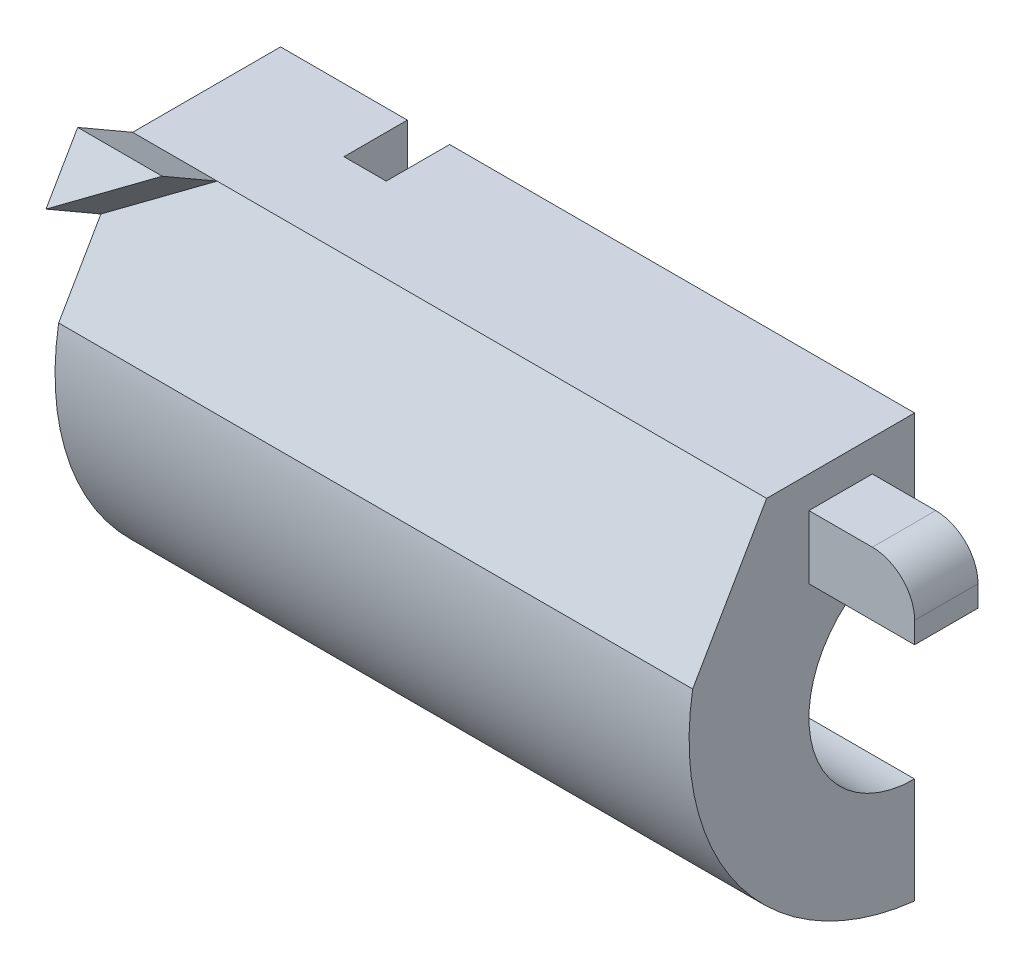
from build123d import *

# Parameters (mm, degrees)
BOSS_EXTRUDE1_DEPTH = 30
CUT_EXTRUDE1_DEPTH  = 10
CUT_EXTRUDE2_DEPTH  = 10
SKETCH5_W           = 3
SKETCH5_H           = 3
BOSS_EXTRUDE2_DEPTH = 5
FILLET2_R           = 2
SKETCH7_W           = 2
SKETCH7_H           = 3
CUT_EXTRUDE3_DEPTH  = 8.5
BOSS_EXTRUDE3_DEPTH = 3


with BuildPart() as part:
    # Sketch2 → Boss-Extrude1 (new body)
    with BuildSketch(Plane(origin=(0, 0, 0), x_dir=(0, 0, -1), z_dir=(1, 0, 0))):
        with BuildLine():
            Line((0, -10), (0, 10))
            Line((0, 10), (-7, 10))
            Line((-7, 10), (-10.5, 3.937822174))
            ThreePointArc((-10.5, 3.937822174), (-8.25442165, -5.294457389), (0, -10))
        make_face()
    extrude(amount=-BOSS_EXTRUDE1_DEPTH)

    # Sketch3 → Cut-Extrude1 (cut)
    with BuildSketch(Plane(origin=(0, 0, 0), x_dir=(0, 0, -1), z_dir=(1, 0, 0))):
        with BuildLine():
            Line((0, -5), (0, 5))
            ThreePointArc((0, 5), (-5, 0), (0, -5))
        make_face()
    extrude(amount=-CUT_EXTRUDE1_DEPTH, mode=Mode.SUBTRACT)

    # Sketch4 → Cut-Extrude2 (cut)
    with BuildSketch(Plane.ZY.offset(30)):
        with BuildLine():
            Line((0, -3), (0, 3))
            ThreePointArc((0, 3), (3, 0), (0, -3))
        make_face()
    extrude(amount=-CUT_EXTRUDE2_DEPTH, mode=Mode.SUBTRACT)

    # Sketch5 → Boss-Extrude2 (add)
    with BuildSketch(Plane(origin=(0, 0, 0), x_dir=(0, 0, -1), z_dir=(1, 0, 0))):
        with Locations((-3.5, 7)):
            Rectangle(SKETCH5_W, SKETCH5_H)
    extrude(amount=BOSS_EXTRUDE2_DEPTH)

    # Fillet2
    fillet2_edges = [part.edges().sort_by_distance(p)[0] for p in [
        (5, 8.5, 3.5),
    ]]
    fillet(fillet2_edges, radius=FILLET2_R)

    # Sketch7 → Cut-Extrude3 (cut)
    with BuildSketch(Plane(origin=(0, 10, 0), x_dir=(1, 0, 0), z_dir=(0, 1, 0))):
        with Locations((-23, -1.5)):
            Rectangle(SKETCH7_W, SKETCH7_H)
    extrude(amount=-CUT_EXTRUDE3_DEPTH, mode=Mode.SUBTRACT)

    # Sketch8 → Boss-Extrude3 (add)
    with BuildSketch(Plane(origin=(0, 5.531088913, 9.580127019), x_dir=(1, 0, 0), z_dir=(0, 0.5, 0.866025404))):
        Polygon((-30, 2.160254038), (-26, 5.160254038), (-30, 5.160254038), align=None)
    extrude(amount=BOSS_EXTRUDE3_DEPTH)


solid = part.part
